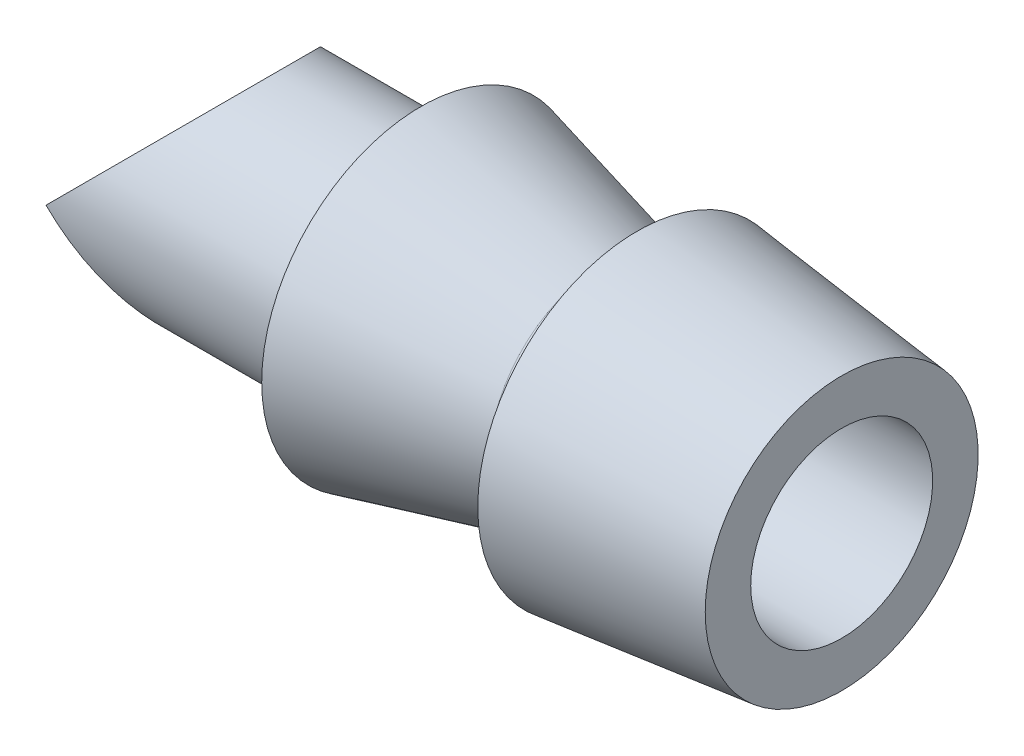
from build123d import *

# Parameters (mm, degrees)
CUT_EXTRUDE3_DEPTH      = 4.5
CUT_EXTRUDE3_DEPTH_BACK = 4.5


with BuildPart() as part:
    # Sketch1 → Revolve1 (revolve)
    with BuildSketch(Plane.XY):
        Polygon((10.63699913, 3), (6.13699913, 3.5), (6.13699913, 2.5), (5.38699913, 2.5), (1.38699913, 3.5), (1.38699913, 2.5), (-4.354665221, 2.5), (-4.354665221, 2), (10.63699913, 2), align=None)
    revolve(axis=Axis((0, 0, 0), (1, 0, 0)))

    # Sketch2 → Cut-Extrude3 (cut, two sides)
    with BuildSketch(Plane.XY) as cut_extrude3_sk:
        Polygon((-1.854665221, 2.5), (-4.354665221, 2.5), (-4.354665221, 0), align=None)
        Polygon((-4.354665221, -2.5), (-4.354665221, 0), (-1.854665221, -2.5), align=None)
    extrude(amount=CUT_EXTRUDE3_DEPTH, mode=Mode.SUBTRACT)
    extrude(cut_extrude3_sk.sketch, amount=-CUT_EXTRUDE3_DEPTH_BACK, mode=Mode.SUBTRACT)


solid = part.part
